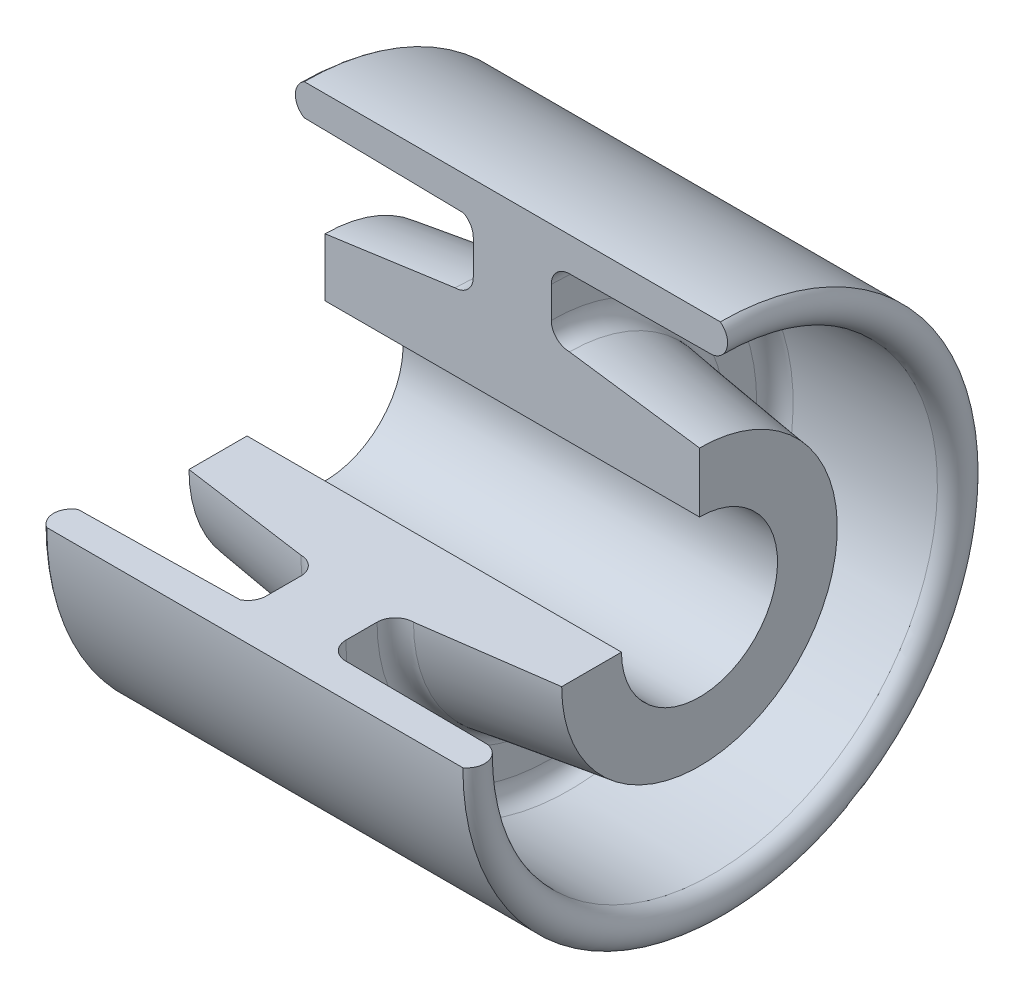
from build123d import *

# Parameters (mm, degrees)
REVOLVE2_ANGLE = 270


with BuildPart() as part:
    # Sketch1 → Revolve2 (revolve)
    with BuildSketch(Plane.XY):
        with BuildLine():
            Line((-50.632149816, 30.528207977), (29.367850184, 30.528207977))
            ThreePointArc((29.367850184, 30.528207977), (30.674979125, 26.908813233), (27.867850184, 24.276583855))
            Line((27.867850184, 24.276583855), (0.367850184, 24.028207977))
            ThreePointArc((0.367850184, 24.028207977), (-2.10702355, 23.003081711), (-3.132149816, 20.528207977))
            Line((-3.132149816, 20.528207977), (-3.132149816, 14.528207977))
            ThreePointArc((-3.132149816, 14.528207977), (-2.10702355, 12.053334243), (0.367850184, 11.028207977))
            Line((0.367850184, 11.028207977), (25.367850184, 7.528207977))
            Line((25.367850184, 7.528207977), (25.367850184, -3.971792023))
            Line((25.367850184, -3.971792023), (-46.632149816, -3.971792023))
            Line((-46.632149816, -3.971792023), (-46.632149816, 7.190485637))
            Line((-46.632149816, 7.190485637), (-21.632149816, 10.690485637))
            ThreePointArc((-21.632149816, 10.690485637), (-19.157276082, 11.715611903), (-18.132149816, 14.190485637))
            Line((-18.132149816, 14.190485637), (-18.132149816, 20.865930317))
            ThreePointArc((-18.132149816, 20.865930317), (-18.642058581, 22.685093423), (-20.023209476, 23.974195264))
            Line((-20.023209476, 23.974195264), (-50.632149816, 24.505975141))
            ThreePointArc((-50.632149816, 24.505975141), (-52.348003545, 27.517091559), (-50.632149816, 30.528207977))
        make_face()
    revolve(axis=Axis((35.391313148, -18.971792023, 0), (-1, 0, 0)), revolution_arc=REVOLVE2_ANGLE)


solid = part.part
